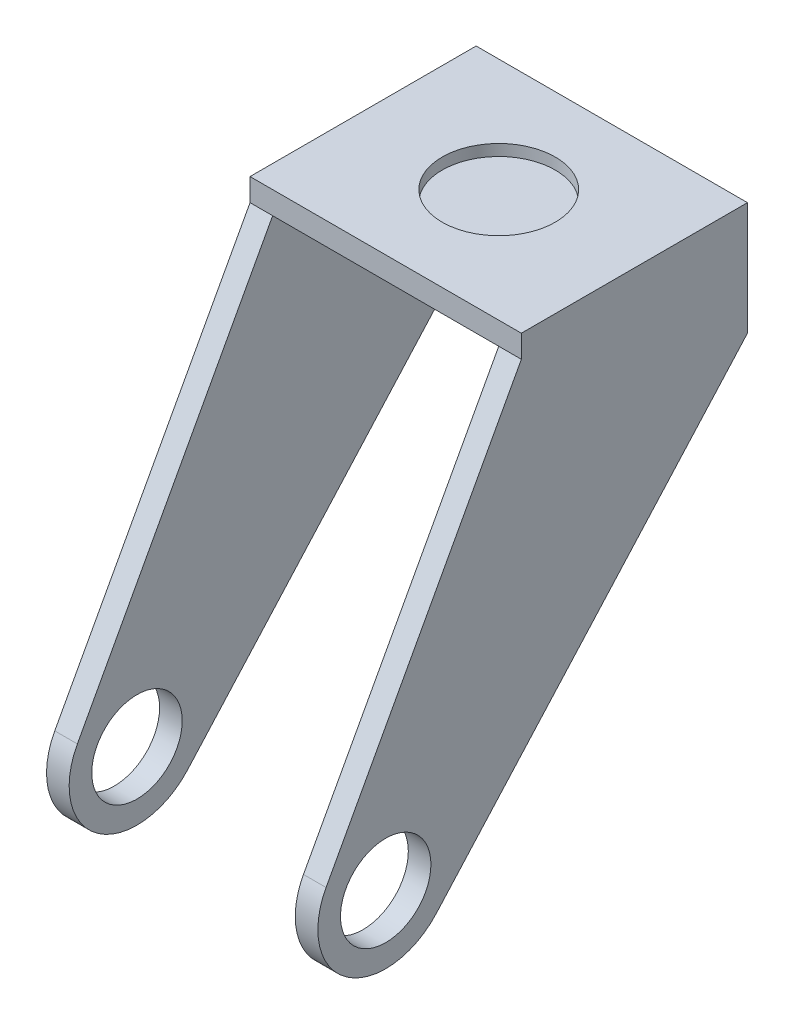
from build123d import *

# Parameters (mm, degrees)
SKETCH1_R           = 10
BOSS_EXTRUDE3_DEPTH = 5
SKETCH3_W           = 60
SKETCH3_H           = 50
BOSS_EXTRUDE4_DEPTH = 5
SKETCH9_R           = 12.5
CUT_EXTRUDE3_DEPTH  = 2.5


with BuildPart() as part:
    # Sketch1 → Boss-Extrude3 (new body)
    with BuildSketch(Plane(origin=(0, 0, 0), x_dir=(0, 0, -1), z_dir=(1, 0, 0))):
        with BuildLine():
            Line((0, 0), (50, 0))
            Line((50, 0), (50, -20))
            Line((50, -20), (-18.826787969, -96.735647895))
            ThreePointArc((-18.826787969, -96.735647895), (-38.641397295, -98.984562701), (-43.183296189, -79.566851328))
            Line((-43.183296189, -79.566851328), (0, 0))
        make_face()
        with Locations((-29.998149885, -86.722822296)):
            Circle(SKETCH1_R, mode=Mode.SUBTRACT)
    extrude(amount=BOSS_EXTRUDE3_DEPTH)


with BuildPart() as body_2:
    # Mirror6: mirrored copy
    add(part.part.mirror(Plane(origin=(30, 0, 0), x_dir=(0, 0, 1), z_dir=(1, 0, 0))))


with BuildPart() as part_1:
    add(part.part)

    add(body_2.part)  # Boss-Extrude4 merges body 2
    # Sketch3 → Boss-Extrude4 (add)
    with BuildSketch(Plane(origin=(0, 0, 0), x_dir=(1, 0, 0), z_dir=(0, 1, 0))):
        with Locations((30, 25)):
            Rectangle(SKETCH3_W, SKETCH3_H)
    extrude(amount=BOSS_EXTRUDE4_DEPTH)

    # Sketch9 → Cut-Extrude3 (cut)
    with BuildSketch(Plane(origin=(0, 5, 0), x_dir=(1, 0, 0), z_dir=(0, 1, 0))):
        with Locations((30, 25)):
            Circle(SKETCH9_R)
    extrude(amount=-CUT_EXTRUDE3_DEPTH, mode=Mode.SUBTRACT)


solid = part_1.part
